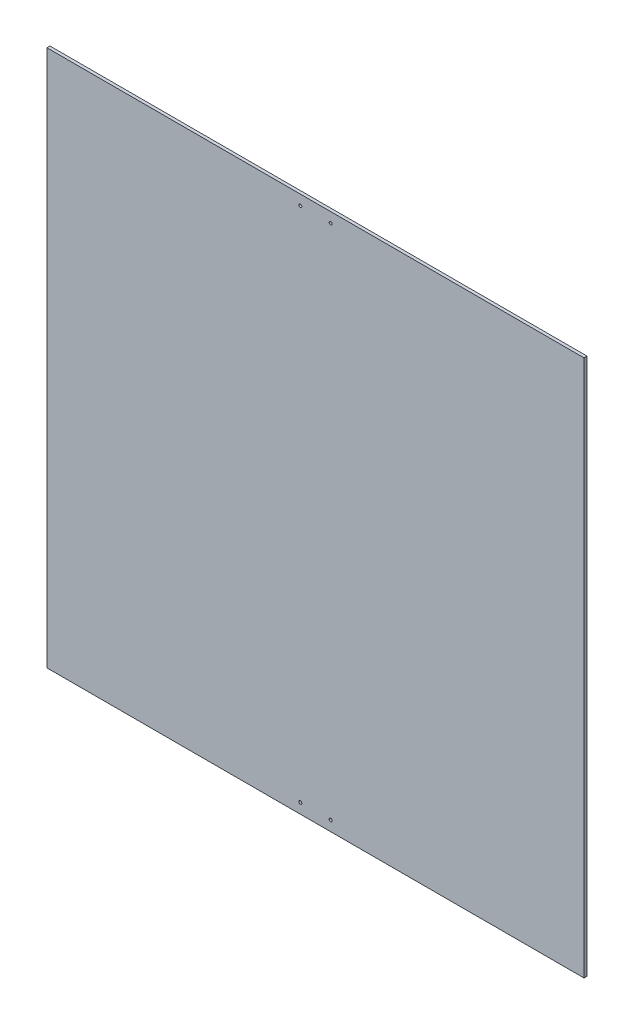
from build123d import *

# Parameters (mm, degrees)
ESQUISSE1_W             = 530
ESQUISSE1_H             = 530
BOSS_EXTRU_1_DEPTH      = 3
ESQUISSE2_R             = 1.5
ENL_V_MAT_EXTRU_1_DEPTH = 3


with BuildPart() as part:
    # Esquisse1 → Boss.-Extru.1 (new body)
    with BuildSketch(Plane.XY):
        with Locations((-265, 265)):
            Rectangle(ESQUISSE1_W, ESQUISSE1_H)
    extrude(amount=BOSS_EXTRU_1_DEPTH)

    # Esquisse2 → Enlèv. mat.-Extru.1 (cut)
    with BuildSketch(Plane.XY.offset(3)):
        with Locations((-250, 520)):
            Circle(ESQUISSE2_R)
        with Locations((-280, 520)):
            Circle(ESQUISSE2_R)
        with Locations((-250, 10)):
            Circle(ESQUISSE2_R)
        with Locations((-280, 10)):
            Circle(ESQUISSE2_R)
    extrude(amount=-ENL_V_MAT_EXTRU_1_DEPTH, mode=Mode.SUBTRACT)


solid = part.part
